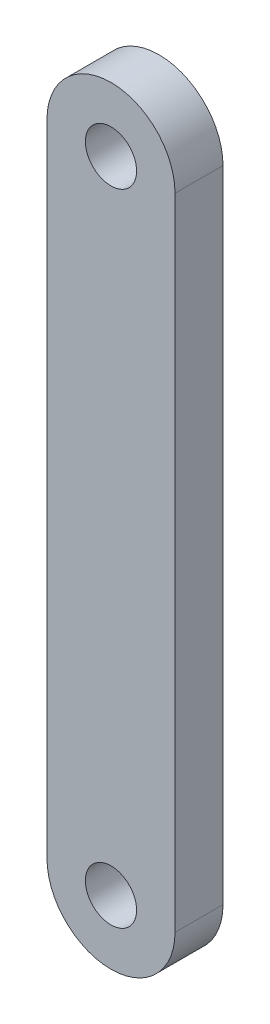
from build123d import *

# Parameters (mm, degrees)
BOSS_EXTRUDE1_DEPTH = 3
SKETCH3_R           = 1.6
CUT_EXTRUDE1_DEPTH  = 4


with BuildPart() as part:
    # Sketch1 → Boss-Extrude1 (new body)
    with BuildSketch(Plane.XY):
        with BuildLine():
            Line((-4, 0), (-4, 40))
            ThreePointArc((-4, 40), (0, 44), (4, 40))
            Line((4, 40), (4, 0))
            ThreePointArc((4, 0), (0, -4), (-4, 0))
        make_face()
    extrude(amount=-BOSS_EXTRUDE1_DEPTH)

    # Sketch3 → Cut-Extrude1 (cut, through all)
    with BuildSketch(Plane.XY):
        Circle(SKETCH3_R)
        with Locations((0, 40)):
            Circle(SKETCH3_R)
    extrude(amount=-CUT_EXTRUDE1_DEPTH, mode=Mode.SUBTRACT)


solid = part.part
